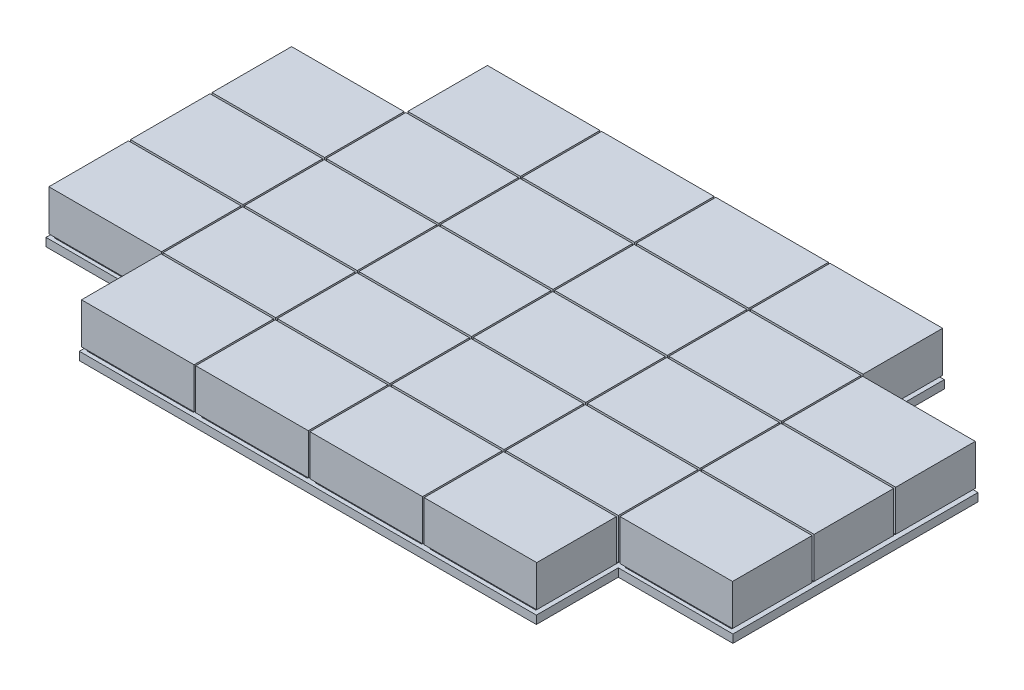
from build123d import *

# Parameters (mm, degrees)
SKETCH1_W                  = 71
SKETCH1_H                  = 250
BOSS_EXTRUDE1_DEPTH        = 5
SKETCH2_W                  = 65
SKETCH2_H                  = 45
BOSS_EXTRUDE3_DEPTH        = 2
LPATTERN1_COUNT            = 5
LPATTERN1_PITCH            = 50
SKETCH3_W                  = 69
SKETCH3_H                  = 48.754858224
BOSS_EXTRUDE8_DEPTH        = 25
LPATTERN5_COUNT            = 5
LPATTERN5_PITCH            = 50
LPATTERN6_COUNT            = 6
LPATTERN6_PITCH            = 70
LPATTERN6_COPY_1_SKETCH_W  = 65
LPATTERN6_COPY_1_SKETCH_H  = 45
LPATTERN6_COPY_1_DEPTH     = 2
LPATTERN6_COPY_2_SKETCH_W  = 65
LPATTERN6_COPY_2_SKETCH_H  = 45
LPATTERN6_COPY_2_DEPTH     = 2
LPATTERN6_COPY_3_SKETCH_W  = 65
LPATTERN6_COPY_3_SKETCH_H  = 45
LPATTERN6_COPY_3_DEPTH     = 2
LPATTERN6_COPY_4_SKETCH_W  = 65
LPATTERN6_COPY_4_SKETCH_H  = 45
LPATTERN6_COPY_4_DEPTH     = 2
LPATTERN6_COPY_5_SKETCH_W  = 65
LPATTERN6_COPY_5_SKETCH_H  = 45
LPATTERN6_COPY_5_DEPTH     = 2
LPATTERN6_COPY_6_SKETCH_W  = 65
LPATTERN6_COPY_6_SKETCH_H  = 45
LPATTERN6_COPY_6_DEPTH     = 2
LPATTERN6_COPY_7_SKETCH_W  = 65
LPATTERN6_COPY_7_SKETCH_H  = 45
LPATTERN6_COPY_7_DEPTH     = 2
LPATTERN6_COPY_8_SKETCH_W  = 65
LPATTERN6_COPY_8_SKETCH_H  = 45
LPATTERN6_COPY_8_DEPTH     = 2
LPATTERN6_COPY_9_SKETCH_W  = 65
LPATTERN6_COPY_9_SKETCH_H  = 45
LPATTERN6_COPY_9_DEPTH     = 2
LPATTERN6_COPY_10_SKETCH_W = 65
LPATTERN6_COPY_10_SKETCH_H = 45
LPATTERN6_COPY_10_DEPTH    = 2
LPATTERN6_COPY_11_SKETCH_W = 65
LPATTERN6_COPY_11_SKETCH_H = 45
LPATTERN6_COPY_11_DEPTH    = 2
LPATTERN6_COPY_12_SKETCH_W = 65
LPATTERN6_COPY_12_SKETCH_H = 45
LPATTERN6_COPY_12_DEPTH    = 2
LPATTERN6_COPY_13_SKETCH_W = 65
LPATTERN6_COPY_13_SKETCH_H = 45
LPATTERN6_COPY_13_DEPTH    = 2
LPATTERN6_COPY_14_SKETCH_W = 65
LPATTERN6_COPY_14_SKETCH_H = 45
LPATTERN6_COPY_14_DEPTH    = 2
LPATTERN6_COPY_15_SKETCH_W = 65
LPATTERN6_COPY_15_SKETCH_H = 45
LPATTERN6_COPY_15_DEPTH    = 2
LPATTERN6_COPY_16_SKETCH_W = 65
LPATTERN6_COPY_16_SKETCH_H = 45
LPATTERN6_COPY_16_DEPTH    = 2
LPATTERN6_COPY_17_SKETCH_W = 65
LPATTERN6_COPY_17_SKETCH_H = 45
LPATTERN6_COPY_17_DEPTH    = 2
LPATTERN6_COPY_18_SKETCH_W = 65
LPATTERN6_COPY_18_SKETCH_H = 45
LPATTERN6_COPY_18_DEPTH    = 2
LPATTERN6_COPY_19_SKETCH_W = 65
LPATTERN6_COPY_19_SKETCH_H = 45
LPATTERN6_COPY_19_DEPTH    = 2
LPATTERN6_COPY_20_SKETCH_W = 65
LPATTERN6_COPY_20_SKETCH_H = 45
LPATTERN6_COPY_20_DEPTH    = 2
LPATTERN6_COPY_21_SKETCH_W = 69
LPATTERN6_COPY_21_SKETCH_H = 48.754858224
LPATTERN6_COPY_21_DEPTH    = 25
LPATTERN6_COPY_22_SKETCH_W = 69
LPATTERN6_COPY_22_SKETCH_H = 48.754858224
LPATTERN6_COPY_22_DEPTH    = 25
LPATTERN6_COPY_23_SKETCH_W = 69
LPATTERN6_COPY_23_SKETCH_H = 48.754858224
LPATTERN6_COPY_23_DEPTH    = 25
LPATTERN6_COPY_24_SKETCH_W = 69
LPATTERN6_COPY_24_SKETCH_H = 48.754858224
LPATTERN6_COPY_24_DEPTH    = 25
LPATTERN6_COPY_25_SKETCH_W = 69
LPATTERN6_COPY_25_SKETCH_H = 48.754858224
LPATTERN6_COPY_25_DEPTH    = 25
LPATTERN6_COPY_26_SKETCH_W = 69
LPATTERN6_COPY_26_SKETCH_H = 48.754858224
LPATTERN6_COPY_26_DEPTH    = 25
LPATTERN6_COPY_27_SKETCH_W = 69
LPATTERN6_COPY_27_SKETCH_H = 48.754858224
LPATTERN6_COPY_27_DEPTH    = 25
LPATTERN6_COPY_28_SKETCH_W = 69
LPATTERN6_COPY_28_SKETCH_H = 48.754858224
LPATTERN6_COPY_28_DEPTH    = 25
LPATTERN6_COPY_29_SKETCH_W = 69
LPATTERN6_COPY_29_SKETCH_H = 48.754858224
LPATTERN6_COPY_29_DEPTH    = 25
LPATTERN6_COPY_30_SKETCH_W = 69
LPATTERN6_COPY_30_SKETCH_H = 48.754858224
LPATTERN6_COPY_30_DEPTH    = 25
LPATTERN6_COPY_31_SKETCH_W = 69
LPATTERN6_COPY_31_SKETCH_H = 48.754858224
LPATTERN6_COPY_31_DEPTH    = 25
LPATTERN6_COPY_32_SKETCH_W = 69
LPATTERN6_COPY_32_SKETCH_H = 48.754858224
LPATTERN6_COPY_32_DEPTH    = 25
LPATTERN6_COPY_33_SKETCH_W = 69
LPATTERN6_COPY_33_SKETCH_H = 48.754858224
LPATTERN6_COPY_33_DEPTH    = 25
LPATTERN6_COPY_34_SKETCH_W = 69
LPATTERN6_COPY_34_SKETCH_H = 48.754858224
LPATTERN6_COPY_34_DEPTH    = 25
LPATTERN6_COPY_35_SKETCH_W = 69
LPATTERN6_COPY_35_SKETCH_H = 48.754858224
LPATTERN6_COPY_35_DEPTH    = 25
LPATTERN6_COPY_36_SKETCH_W = 69
LPATTERN6_COPY_36_SKETCH_H = 48.754858224
LPATTERN6_COPY_36_DEPTH    = 25
LPATTERN6_COPY_37_SKETCH_W = 69
LPATTERN6_COPY_37_SKETCH_H = 48.754858224
LPATTERN6_COPY_37_DEPTH    = 25
LPATTERN6_COPY_38_SKETCH_W = 69
LPATTERN6_COPY_38_SKETCH_H = 48.754858224
LPATTERN6_COPY_38_DEPTH    = 25
LPATTERN6_COPY_39_SKETCH_W = 69
LPATTERN6_COPY_39_SKETCH_H = 48.754858224
LPATTERN6_COPY_39_DEPTH    = 25
LPATTERN6_COPY_40_SKETCH_W = 69
LPATTERN6_COPY_40_SKETCH_H = 48.754858224
LPATTERN6_COPY_40_DEPTH    = 25
SKETCH6_W                  = 70.91813163
SKETCH6_H                  = 50.446918376
SKETCH6_W_2                = 72.16397651
SKETCH6_H_2                = 50.963322749
SKETCH6_W_3                = 73.335157995
SKETCH6_H_3                = 52.222653486
SKETCH6_H_4                = 55.748948003
CUT_EXTRUDE1_DEPTH         = 28
CUT_EXTRUDE1_DEPTH_BACK    = 6


with BuildPart() as part:
    # Sketch1 → Boss-Extrude1 (new body)
    with BuildSketch(Plane(origin=(0, 0, 0), x_dir=(1, 0, 0), z_dir=(0, 1, 0))):
        Rectangle(SKETCH1_W, SKETCH1_H)
    boss_extrude1 = extrude(amount=BOSS_EXTRUDE1_DEPTH)

    # Sketch2 → Boss-Extrude3 (add)
    with BuildSketch(Plane(origin=(0, 5, 0), x_dir=(1, 0, 0), z_dir=(0, 1, 0))):
        with Locations((0, -100)):
            Rectangle(SKETCH2_W, SKETCH2_H)
    boss_extrude3 = extrude(amount=BOSS_EXTRUDE3_DEPTH)

    # LPattern1: Boss-Extrude3 ×5
    with Locations(*[(0, 0, -i * LPATTERN1_PITCH) for i in range(1, LPATTERN1_COUNT)]):
        add(boss_extrude3)

    # Sketch3 → Boss-Extrude8 (add)
    with BuildSketch(Plane(origin=(0, 7, 0), x_dir=(1, 0, 0), z_dir=(0, 1, 0))):
        with Locations((0, -99.635002086)):
            Rectangle(SKETCH3_W, SKETCH3_H)
    boss_extrude8 = extrude(amount=BOSS_EXTRUDE8_DEPTH)

    # LPattern5: Boss-Extrude8 ×5
    with Locations(*[(0, 0, -i * LPATTERN5_PITCH) for i in range(1, LPATTERN5_COUNT)]):
        add(boss_extrude8)

    # LPattern6: Boss-Extrude1, Boss-Extrude3, Boss-Extrude8 ×6
    with Locations(*[(i * LPATTERN6_PITCH, 0, 0) for i in range(1, LPATTERN6_COUNT)]):
        add(boss_extrude1)
        add(boss_extrude3)
        add(boss_extrude8)

    # LPattern6 copy 1 sketch → LPattern6 copy 1 (add)
    with BuildSketch(Plane(origin=(70, 5, -50), x_dir=(1, 0, 0), z_dir=(0, 1, 0))):
        with Locations((0, -100)):
            Rectangle(LPATTERN6_COPY_1_SKETCH_W, LPATTERN6_COPY_1_SKETCH_H)
    extrude(amount=LPATTERN6_COPY_1_DEPTH)

    # LPattern6 copy 2 sketch → LPattern6 copy 2 (add)
    with BuildSketch(Plane(origin=(140, 5, -50), x_dir=(1, 0, 0), z_dir=(0, 1, 0))):
        with Locations((0, -100)):
            Rectangle(LPATTERN6_COPY_2_SKETCH_W, LPATTERN6_COPY_2_SKETCH_H)
    extrude(amount=LPATTERN6_COPY_2_DEPTH)

    # LPattern6 copy 3 sketch → LPattern6 copy 3 (add)
    with BuildSketch(Plane(origin=(210, 5, -50), x_dir=(1, 0, 0), z_dir=(0, 1, 0))):
        with Locations((0, -100)):
            Rectangle(LPATTERN6_COPY_3_SKETCH_W, LPATTERN6_COPY_3_SKETCH_H)
    extrude(amount=LPATTERN6_COPY_3_DEPTH)

    # LPattern6 copy 4 sketch → LPattern6 copy 4 (add)
    with BuildSketch(Plane(origin=(280, 5, -50), x_dir=(1, 0, 0), z_dir=(0, 1, 0))):
        with Locations((0, -100)):
            Rectangle(LPATTERN6_COPY_4_SKETCH_W, LPATTERN6_COPY_4_SKETCH_H)
    extrude(amount=LPATTERN6_COPY_4_DEPTH)

    # LPattern6 copy 5 sketch → LPattern6 copy 5 (add)
    with BuildSketch(Plane(origin=(350, 5, -50), x_dir=(1, 0, 0), z_dir=(0, 1, 0))):
        with Locations((0, -100)):
            Rectangle(LPATTERN6_COPY_5_SKETCH_W, LPATTERN6_COPY_5_SKETCH_H)
    extrude(amount=LPATTERN6_COPY_5_DEPTH)

    # LPattern6 copy 6 sketch → LPattern6 copy 6 (add)
    with BuildSketch(Plane(origin=(70, 5, -100), x_dir=(1, 0, 0), z_dir=(0, 1, 0))):
        with Locations((0, -100)):
            Rectangle(LPATTERN6_COPY_6_SKETCH_W, LPATTERN6_COPY_6_SKETCH_H)
    extrude(amount=LPATTERN6_COPY_6_DEPTH)

    # LPattern6 copy 7 sketch → LPattern6 copy 7 (add)
    with BuildSketch(Plane(origin=(140, 5, -100), x_dir=(1, 0, 0), z_dir=(0, 1, 0))):
        with Locations((0, -100)):
            Rectangle(LPATTERN6_COPY_7_SKETCH_W, LPATTERN6_COPY_7_SKETCH_H)
    extrude(amount=LPATTERN6_COPY_7_DEPTH)

    # LPattern6 copy 8 sketch → LPattern6 copy 8 (add)
    with BuildSketch(Plane(origin=(210, 5, -100), x_dir=(1, 0, 0), z_dir=(0, 1, 0))):
        with Locations((0, -100)):
            Rectangle(LPATTERN6_COPY_8_SKETCH_W, LPATTERN6_COPY_8_SKETCH_H)
    extrude(amount=LPATTERN6_COPY_8_DEPTH)

    # LPattern6 copy 9 sketch → LPattern6 copy 9 (add)
    with BuildSketch(Plane(origin=(280, 5, -100), x_dir=(1, 0, 0), z_dir=(0, 1, 0))):
        with Locations((0, -100)):
            Rectangle(LPATTERN6_COPY_9_SKETCH_W, LPATTERN6_COPY_9_SKETCH_H)
    extrude(amount=LPATTERN6_COPY_9_DEPTH)

    # LPattern6 copy 10 sketch → LPattern6 copy 10 (add)
    with BuildSketch(Plane(origin=(350, 5, -100), x_dir=(1, 0, 0), z_dir=(0, 1, 0))):
        with Locations((0, -100)):
            Rectangle(LPATTERN6_COPY_10_SKETCH_W, LPATTERN6_COPY_10_SKETCH_H)
    extrude(amount=LPATTERN6_COPY_10_DEPTH)

    # LPattern6 copy 11 sketch → LPattern6 copy 11 (add)
    with BuildSketch(Plane(origin=(70, 5, -150), x_dir=(1, 0, 0), z_dir=(0, 1, 0))):
        with Locations((0, -100)):
            Rectangle(LPATTERN6_COPY_11_SKETCH_W, LPATTERN6_COPY_11_SKETCH_H)
    extrude(amount=LPATTERN6_COPY_11_DEPTH)

    # LPattern6 copy 12 sketch → LPattern6 copy 12 (add)
    with BuildSketch(Plane(origin=(140, 5, -150), x_dir=(1, 0, 0), z_dir=(0, 1, 0))):
        with Locations((0, -100)):
            Rectangle(LPATTERN6_COPY_12_SKETCH_W, LPATTERN6_COPY_12_SKETCH_H)
    extrude(amount=LPATTERN6_COPY_12_DEPTH)

    # LPattern6 copy 13 sketch → LPattern6 copy 13 (add)
    with BuildSketch(Plane(origin=(210, 5, -150), x_dir=(1, 0, 0), z_dir=(0, 1, 0))):
        with Locations((0, -100)):
            Rectangle(LPATTERN6_COPY_13_SKETCH_W, LPATTERN6_COPY_13_SKETCH_H)
    extrude(amount=LPATTERN6_COPY_13_DEPTH)

    # LPattern6 copy 14 sketch → LPattern6 copy 14 (add)
    with BuildSketch(Plane(origin=(280, 5, -150), x_dir=(1, 0, 0), z_dir=(0, 1, 0))):
        with Locations((0, -100)):
            Rectangle(LPATTERN6_COPY_14_SKETCH_W, LPATTERN6_COPY_14_SKETCH_H)
    extrude(amount=LPATTERN6_COPY_14_DEPTH)

    # LPattern6 copy 15 sketch → LPattern6 copy 15 (add)
    with BuildSketch(Plane(origin=(350, 5, -150), x_dir=(1, 0, 0), z_dir=(0, 1, 0))):
        with Locations((0, -100)):
            Rectangle(LPATTERN6_COPY_15_SKETCH_W, LPATTERN6_COPY_15_SKETCH_H)
    extrude(amount=LPATTERN6_COPY_15_DEPTH)

    # LPattern6 copy 16 sketch → LPattern6 copy 16 (add)
    with BuildSketch(Plane(origin=(70, 5, -200), x_dir=(1, 0, 0), z_dir=(0, 1, 0))):
        with Locations((0, -100)):
            Rectangle(LPATTERN6_COPY_16_SKETCH_W, LPATTERN6_COPY_16_SKETCH_H)
    extrude(amount=LPATTERN6_COPY_16_DEPTH)

    # LPattern6 copy 17 sketch → LPattern6 copy 17 (add)
    with BuildSketch(Plane(origin=(140, 5, -200), x_dir=(1, 0, 0), z_dir=(0, 1, 0))):
        with Locations((0, -100)):
            Rectangle(LPATTERN6_COPY_17_SKETCH_W, LPATTERN6_COPY_17_SKETCH_H)
    extrude(amount=LPATTERN6_COPY_17_DEPTH)

    # LPattern6 copy 18 sketch → LPattern6 copy 18 (add)
    with BuildSketch(Plane(origin=(210, 5, -200), x_dir=(1, 0, 0), z_dir=(0, 1, 0))):
        with Locations((0, -100)):
            Rectangle(LPATTERN6_COPY_18_SKETCH_W, LPATTERN6_COPY_18_SKETCH_H)
    extrude(amount=LPATTERN6_COPY_18_DEPTH)

    # LPattern6 copy 19 sketch → LPattern6 copy 19 (add)
    with BuildSketch(Plane(origin=(280, 5, -200), x_dir=(1, 0, 0), z_dir=(0, 1, 0))):
        with Locations((0, -100)):
            Rectangle(LPATTERN6_COPY_19_SKETCH_W, LPATTERN6_COPY_19_SKETCH_H)
    extrude(amount=LPATTERN6_COPY_19_DEPTH)

    # LPattern6 copy 20 sketch → LPattern6 copy 20 (add)
    with BuildSketch(Plane(origin=(350, 5, -200), x_dir=(1, 0, 0), z_dir=(0, 1, 0))):
        with Locations((0, -100)):
            Rectangle(LPATTERN6_COPY_20_SKETCH_W, LPATTERN6_COPY_20_SKETCH_H)
    extrude(amount=LPATTERN6_COPY_20_DEPTH)

    # LPattern6 copy 21 sketch → LPattern6 copy 21 (add)
    with BuildSketch(Plane(origin=(70, 7, -50), x_dir=(1, 0, 0), z_dir=(0, 1, 0))):
        with Locations((0, -99.635002086)):
            Rectangle(LPATTERN6_COPY_21_SKETCH_W, LPATTERN6_COPY_21_SKETCH_H)
    extrude(amount=LPATTERN6_COPY_21_DEPTH)

    # LPattern6 copy 22 sketch → LPattern6 copy 22 (add)
    with BuildSketch(Plane(origin=(140, 7, -50), x_dir=(1, 0, 0), z_dir=(0, 1, 0))):
        with Locations((0, -99.635002086)):
            Rectangle(LPATTERN6_COPY_22_SKETCH_W, LPATTERN6_COPY_22_SKETCH_H)
    extrude(amount=LPATTERN6_COPY_22_DEPTH)

    # LPattern6 copy 23 sketch → LPattern6 copy 23 (add)
    with BuildSketch(Plane(origin=(210, 7, -50), x_dir=(1, 0, 0), z_dir=(0, 1, 0))):
        with Locations((0, -99.635002086)):
            Rectangle(LPATTERN6_COPY_23_SKETCH_W, LPATTERN6_COPY_23_SKETCH_H)
    extrude(amount=LPATTERN6_COPY_23_DEPTH)

    # LPattern6 copy 24 sketch → LPattern6 copy 24 (add)
    with BuildSketch(Plane(origin=(280, 7, -50), x_dir=(1, 0, 0), z_dir=(0, 1, 0))):
        with Locations((0, -99.635002086)):
            Rectangle(LPATTERN6_COPY_24_SKETCH_W, LPATTERN6_COPY_24_SKETCH_H)
    extrude(amount=LPATTERN6_COPY_24_DEPTH)

    # LPattern6 copy 25 sketch → LPattern6 copy 25 (add)
    with BuildSketch(Plane(origin=(350, 7, -50), x_dir=(1, 0, 0), z_dir=(0, 1, 0))):
        with Locations((0, -99.635002086)):
            Rectangle(LPATTERN6_COPY_25_SKETCH_W, LPATTERN6_COPY_25_SKETCH_H)
    extrude(amount=LPATTERN6_COPY_25_DEPTH)

    # LPattern6 copy 26 sketch → LPattern6 copy 26 (add)
    with BuildSketch(Plane(origin=(70, 7, -100), x_dir=(1, 0, 0), z_dir=(0, 1, 0))):
        with Locations((0, -99.635002086)):
            Rectangle(LPATTERN6_COPY_26_SKETCH_W, LPATTERN6_COPY_26_SKETCH_H)
    extrude(amount=LPATTERN6_COPY_26_DEPTH)

    # LPattern6 copy 27 sketch → LPattern6 copy 27 (add)
    with BuildSketch(Plane(origin=(140, 7, -100), x_dir=(1, 0, 0), z_dir=(0, 1, 0))):
        with Locations((0, -99.635002086)):
            Rectangle(LPATTERN6_COPY_27_SKETCH_W, LPATTERN6_COPY_27_SKETCH_H)
    extrude(amount=LPATTERN6_COPY_27_DEPTH)

    # LPattern6 copy 28 sketch → LPattern6 copy 28 (add)
    with BuildSketch(Plane(origin=(210, 7, -100), x_dir=(1, 0, 0), z_dir=(0, 1, 0))):
        with Locations((0, -99.635002086)):
            Rectangle(LPATTERN6_COPY_28_SKETCH_W, LPATTERN6_COPY_28_SKETCH_H)
    extrude(amount=LPATTERN6_COPY_28_DEPTH)

    # LPattern6 copy 29 sketch → LPattern6 copy 29 (add)
    with BuildSketch(Plane(origin=(280, 7, -100), x_dir=(1, 0, 0), z_dir=(0, 1, 0))):
        with Locations((0, -99.635002086)):
            Rectangle(LPATTERN6_COPY_29_SKETCH_W, LPATTERN6_COPY_29_SKETCH_H)
    extrude(amount=LPATTERN6_COPY_29_DEPTH)

    # LPattern6 copy 30 sketch → LPattern6 copy 30 (add)
    with BuildSketch(Plane(origin=(350, 7, -100), x_dir=(1, 0, 0), z_dir=(0, 1, 0))):
        with Locations((0, -99.635002086)):
            Rectangle(LPATTERN6_COPY_30_SKETCH_W, LPATTERN6_COPY_30_SKETCH_H)
    extrude(amount=LPATTERN6_COPY_30_DEPTH)

    # LPattern6 copy 31 sketch → LPattern6 copy 31 (add)
    with BuildSketch(Plane(origin=(70, 7, -150), x_dir=(1, 0, 0), z_dir=(0, 1, 0))):
        with Locations((0, -99.635002086)):
            Rectangle(LPATTERN6_COPY_31_SKETCH_W, LPATTERN6_COPY_31_SKETCH_H)
    extrude(amount=LPATTERN6_COPY_31_DEPTH)

    # LPattern6 copy 32 sketch → LPattern6 copy 32 (add)
    with BuildSketch(Plane(origin=(140, 7, -150), x_dir=(1, 0, 0), z_dir=(0, 1, 0))):
        with Locations((0, -99.635002086)):
            Rectangle(LPATTERN6_COPY_32_SKETCH_W, LPATTERN6_COPY_32_SKETCH_H)
    extrude(amount=LPATTERN6_COPY_32_DEPTH)

    # LPattern6 copy 33 sketch → LPattern6 copy 33 (add)
    with BuildSketch(Plane(origin=(210, 7, -150), x_dir=(1, 0, 0), z_dir=(0, 1, 0))):
        with Locations((0, -99.635002086)):
            Rectangle(LPATTERN6_COPY_33_SKETCH_W, LPATTERN6_COPY_33_SKETCH_H)
    extrude(amount=LPATTERN6_COPY_33_DEPTH)

    # LPattern6 copy 34 sketch → LPattern6 copy 34 (add)
    with BuildSketch(Plane(origin=(280, 7, -150), x_dir=(1, 0, 0), z_dir=(0, 1, 0))):
        with Locations((0, -99.635002086)):
            Rectangle(LPATTERN6_COPY_34_SKETCH_W, LPATTERN6_COPY_34_SKETCH_H)
    extrude(amount=LPATTERN6_COPY_34_DEPTH)

    # LPattern6 copy 35 sketch → LPattern6 copy 35 (add)
    with BuildSketch(Plane(origin=(350, 7, -150), x_dir=(1, 0, 0), z_dir=(0, 1, 0))):
        with Locations((0, -99.635002086)):
            Rectangle(LPATTERN6_COPY_35_SKETCH_W, LPATTERN6_COPY_35_SKETCH_H)
    extrude(amount=LPATTERN6_COPY_35_DEPTH)

    # LPattern6 copy 36 sketch → LPattern6 copy 36 (add)
    with BuildSketch(Plane(origin=(70, 7, -200), x_dir=(1, 0, 0), z_dir=(0, 1, 0))):
        with Locations((0, -99.635002086)):
            Rectangle(LPATTERN6_COPY_36_SKETCH_W, LPATTERN6_COPY_36_SKETCH_H)
    extrude(amount=LPATTERN6_COPY_36_DEPTH)

    # LPattern6 copy 37 sketch → LPattern6 copy 37 (add)
    with BuildSketch(Plane(origin=(140, 7, -200), x_dir=(1, 0, 0), z_dir=(0, 1, 0))):
        with Locations((0, -99.635002086)):
            Rectangle(LPATTERN6_COPY_37_SKETCH_W, LPATTERN6_COPY_37_SKETCH_H)
    extrude(amount=LPATTERN6_COPY_37_DEPTH)

    # LPattern6 copy 38 sketch → LPattern6 copy 38 (add)
    with BuildSketch(Plane(origin=(210, 7, -200), x_dir=(1, 0, 0), z_dir=(0, 1, 0))):
        with Locations((0, -99.635002086)):
            Rectangle(LPATTERN6_COPY_38_SKETCH_W, LPATTERN6_COPY_38_SKETCH_H)
    extrude(amount=LPATTERN6_COPY_38_DEPTH)

    # LPattern6 copy 39 sketch → LPattern6 copy 39 (add)
    with BuildSketch(Plane(origin=(280, 7, -200), x_dir=(1, 0, 0), z_dir=(0, 1, 0))):
        with Locations((0, -99.635002086)):
            Rectangle(LPATTERN6_COPY_39_SKETCH_W, LPATTERN6_COPY_39_SKETCH_H)
    extrude(amount=LPATTERN6_COPY_39_DEPTH)

    # LPattern6 copy 40 sketch → LPattern6 copy 40 (add)
    with BuildSketch(Plane(origin=(350, 7, -200), x_dir=(1, 0, 0), z_dir=(0, 1, 0))):
        with Locations((0, -99.635002086)):
            Rectangle(LPATTERN6_COPY_40_SKETCH_W, LPATTERN6_COPY_40_SKETCH_H)
    extrude(amount=LPATTERN6_COPY_40_DEPTH)

    # Sketch6 → Cut-Extrude1 (cut, two sides)
    with BuildSketch(Plane(origin=(0, 5, 0), x_dir=(1, 0, 0), z_dir=(0, 1, 0))) as cut_extrude1_sk:
        with Locations((350.717849241, 100.649206162)):
            Rectangle(SKETCH6_W, SKETCH6_H)
        with Locations((351.340771681, -100.256186282)):
            Rectangle(SKETCH6_W_2, SKETCH6_H_2)
        with Locations((-1.505848083, 101.537073717)):
            Rectangle(SKETCH6_W_3, SKETCH6_H_3)
        with Locations((-1.505848083, -102.648998909)):
            Rectangle(SKETCH6_W_3, SKETCH6_H_4)
    extrude(amount=CUT_EXTRUDE1_DEPTH, mode=Mode.SUBTRACT)
    extrude(cut_extrude1_sk.sketch, amount=-CUT_EXTRUDE1_DEPTH_BACK, mode=Mode.SUBTRACT)


solid = part.part
